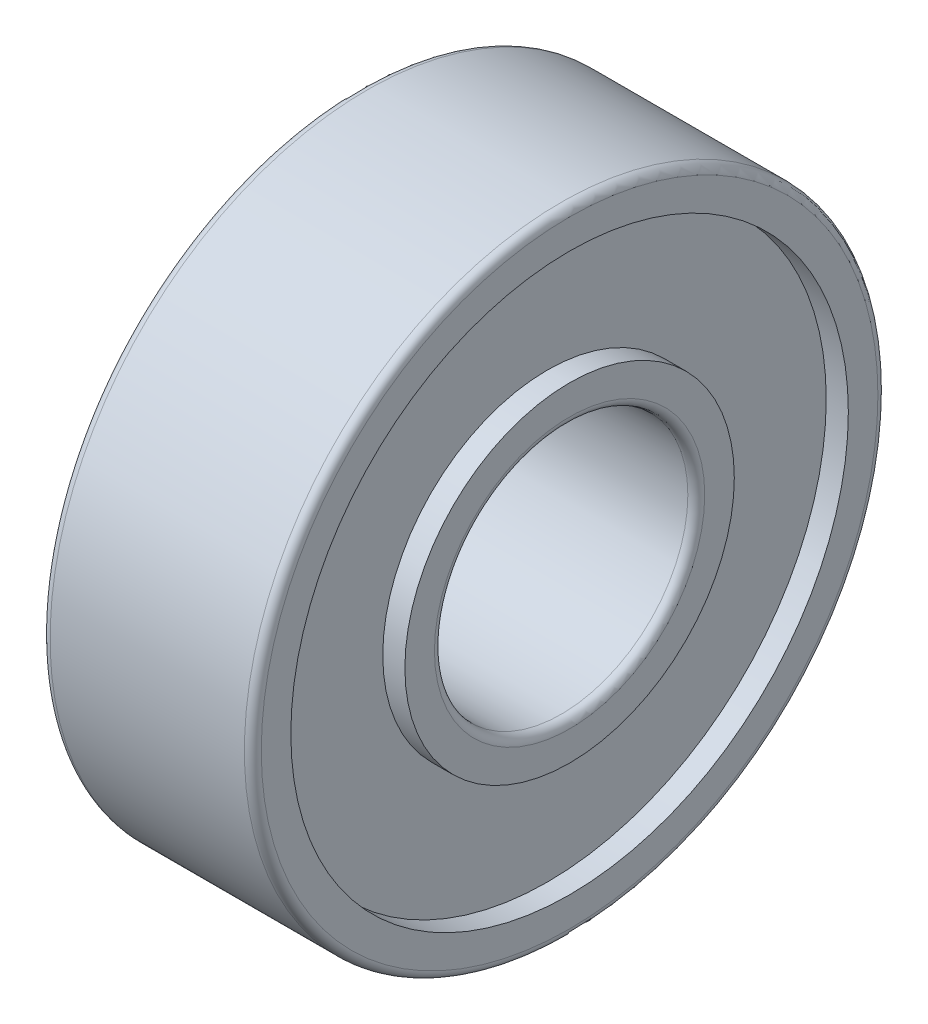
from build123d import *


with BuildPart() as part:
    # Sketch1 → Revolve1 (revolve)
    with BuildSketch(Plane.XY):
        with BuildLine():
            Line((0, 3.9), (0, 3.2))
            ThreePointArc((0, 3.2), (0.058578644, 3.058578644), (0.2, 3))
            Line((0.2, 3), (4.8, 3))
            ThreePointArc((4.8, 3), (4.941421356, 3.058578644), (5, 3.2))
            Line((5, 3.2), (5, 3.9))
            Line((5, 3.9), (4.4765, 3.9))
            Line((4.4765, 3.9), (4.4765, 6.6))
            Line((4.4765, 6.6), (5, 6.6))
            Line((5, 6.6), (5, 7.3))
            ThreePointArc((5, 7.3), (4.941421356, 7.441421356), (4.8, 7.5))
            Line((4.8, 7.5), (0.2, 7.5))
            ThreePointArc((0.2, 7.5), (0.058578644, 7.441421356), (0, 7.3))
            Line((0, 7.3), (0, 6.6))
            Line((0, 6.6), (0.5235, 6.6))
            Line((0.5235, 6.6), (0.5235, 3.9))
            Line((0.5235, 3.9), (0, 3.9))
        make_face()
    revolve(axis=Axis((-0.001349798, 0, 0), (1, 0, 0)))


solid = part.part
